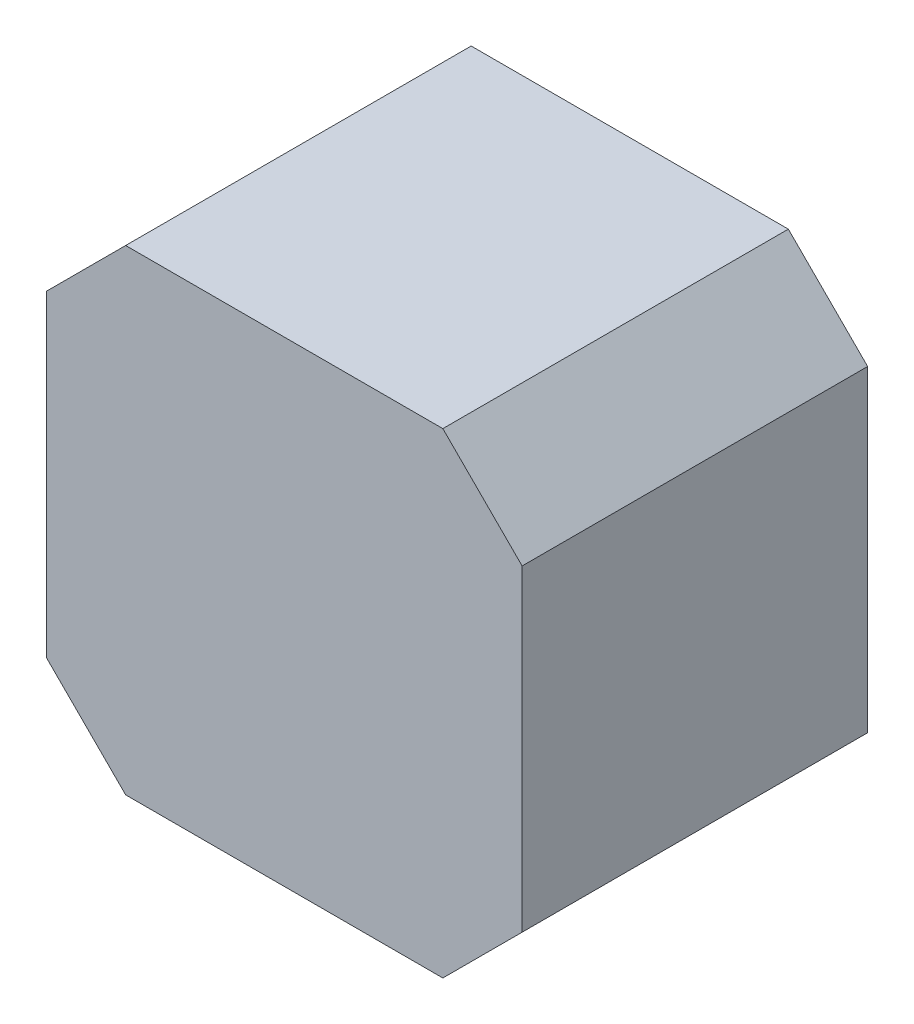
from build123d import *

# Parameters (mm, degrees)
SALIENTE_EXTRUIR1_DEPTH = 30.5


with BuildPart() as part:
    # Croquis1 → Saliente-Extruir1 (new body)
    with BuildSketch(Plane.XY):
        Polygon((-14, 21), (-21, 14), (-21, -14), (-14, -21), (14, -21), (21, -14), (21, 14), (14, 21), align=None)
    extrude(amount=SALIENTE_EXTRUIR1_DEPTH)


solid = part.part
